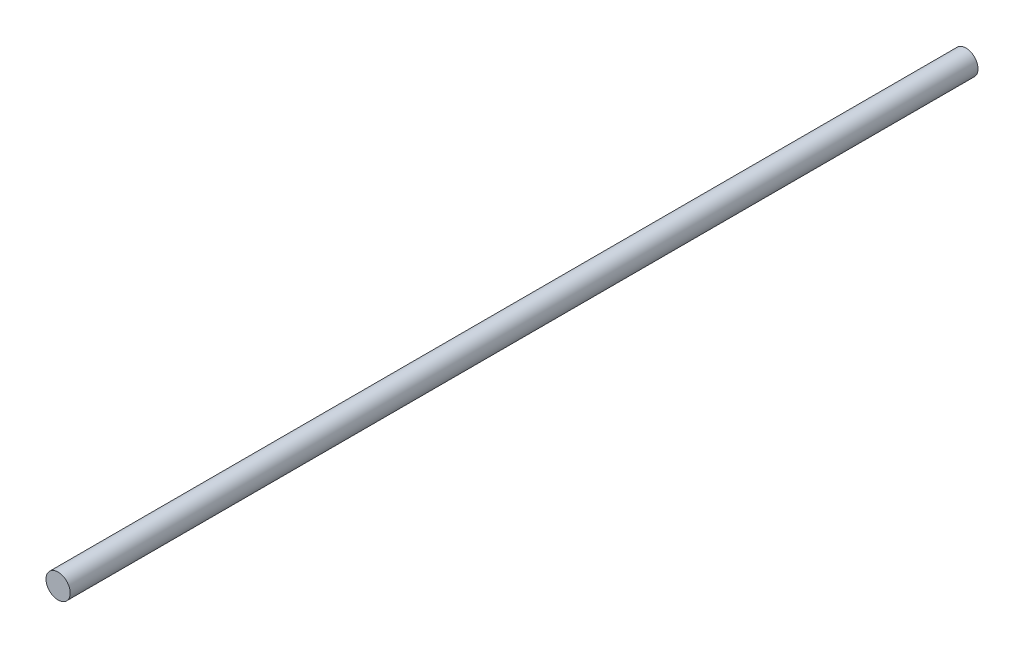
from build123d import *

# Parameters (mm, degrees)
SKETCH1_R           = 4
BOSS_EXTRUDE1_DEPTH = 300


with BuildPart() as part:
    # Sketch1 → Boss-Extrude1 (new body)
    with BuildSketch(Plane.XY):
        with Locations((-3.962490579, 1.930116379)):
            Circle(SKETCH1_R)
    extrude(amount=BOSS_EXTRUDE1_DEPTH)


solid = part.part
